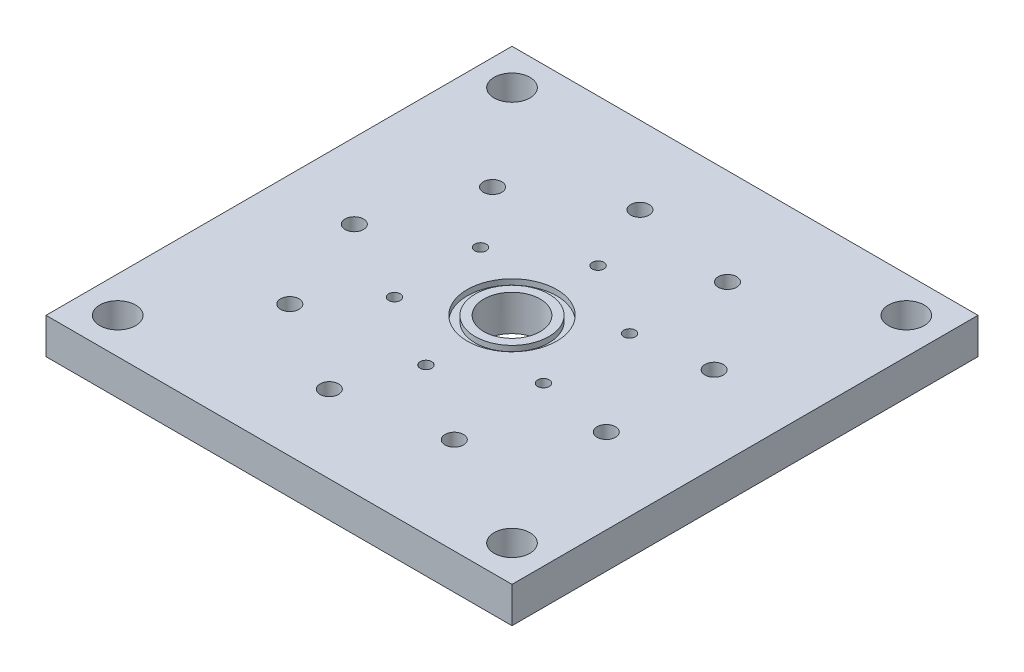
from build123d import *

# Parameters (mm, degrees)
SKETCH1_W           = 82.55
SKETCH1_H           = 82.55
BOSS_EXTRUDE1_DEPTH = 6.35
CUT_EXTRUDE1_REACH  = 8.35
SKETCH2_R           = 4.99999
SKETCH4_R           = 7.9248
SKETCH4_R_2         = 6.5278
CUT_EXTRUDE3_DEPTH  = 0.9779
SKETCH5_R           = 1.03251
CUT_EXTRUDE4_DEPTH  = 3.175
CIRPATTERN1_COUNT   = 6
SKETCH6_R           = 1.63195
CUT_EXTRUDE5_DEPTH  = 6.35
CIRPATTERN2_COUNT   = 9
CUT_EXTRUDE6_REACH  = 8.35
SKETCH7_R           = 3.175


with BuildPart() as part:
    # Sketch1 → Boss-Extrude1 (new body)
    with BuildSketch(Plane(origin=(0, 0, 0), x_dir=(1, 0, 0), z_dir=(0, 1, 0))):
        Rectangle(SKETCH1_W, SKETCH1_H)
    extrude(amount=BOSS_EXTRUDE1_DEPTH)

    # Sketch2 → Cut-Extrude1 (cut, up to next)
    with BuildSketch(Plane(origin=(0, 6.35, 0), x_dir=(1, 0, 0), z_dir=(0, 1, 0)), mode=Mode.PRIVATE) as cut_extrude1_sk1:
        Circle(SKETCH2_R)
    cut_extrude1_tool1 = extrude(cut_extrude1_sk1.sketch, amount=-CUT_EXTRUDE1_REACH, mode=Mode.PRIVATE) & part.part
    add(cut_extrude1_tool1.solids().sort_by_distance((0, 6.35, 0))[0], mode=Mode.SUBTRACT)

    # Sketch4 → Cut-Extrude3 (cut)
    with BuildSketch(Plane(origin=(0, 6.35, 0), x_dir=(1, 0, 0), z_dir=(0, 1, 0))):
        Circle(SKETCH4_R)
        Circle(SKETCH4_R_2, mode=Mode.SUBTRACT)
    extrude(amount=-CUT_EXTRUDE3_DEPTH, mode=Mode.SUBTRACT)

    # Sketch5 → Cut-Extrude4 (cut)
    with BuildSketch(Plane(origin=(0, 6.35, 0), x_dir=(1, 0, 0), z_dir=(0, 1, 0))):
        with Locations((0, -15.24)):
            Circle(SKETCH5_R)
    cut_extrude4 = extrude(amount=-CUT_EXTRUDE4_DEPTH, mode=Mode.SUBTRACT)

    # CirPattern1: Cut-Extrude4 ×6 about axis
    cirpattern1_axis = Axis((0, 0, 0), (0, 1, 0))
    for i in range(1, CIRPATTERN1_COUNT):
        add(cut_extrude4.rotate(cirpattern1_axis, i * 360 / CIRPATTERN1_COUNT), mode=Mode.SUBTRACT)

    # Sketch6 → Cut-Extrude5 (cut)
    with BuildSketch(Plane(origin=(0, 6.35, 0), x_dir=(1, 0, 0), z_dir=(0, 1, 0))):
        with Locations((13.97, -24.196749782)):
            Circle(SKETCH6_R)
    cut_extrude5 = extrude(amount=-CUT_EXTRUDE5_DEPTH, mode=Mode.SUBTRACT)

    # CirPattern2: Cut-Extrude5 ×9 about axis
    cirpattern2_axis = Axis((0, 0, 0), (0, 1, 0))
    for i in range(1, CIRPATTERN2_COUNT):
        add(cut_extrude5.rotate(cirpattern2_axis, i * 360 / CIRPATTERN2_COUNT), mode=Mode.SUBTRACT)

    # Sketch7 → Cut-Extrude6 (cut, up to next)
    with BuildSketch(Plane(origin=(0, 6.35, 0), x_dir=(1, 0, 0), z_dir=(0, 1, 0)), mode=Mode.PRIVATE) as cut_extrude6_sk1:
        with Locations((34.925, 34.925)):
            Circle(SKETCH7_R)
    cut_extrude6_tool1 = extrude(cut_extrude6_sk1.sketch, amount=-CUT_EXTRUDE6_REACH, mode=Mode.PRIVATE) & part.part
    add(cut_extrude6_tool1.solids().sort_by_distance((34.925, 6.35, -34.925))[0], mode=Mode.SUBTRACT)
    # Sketch7 → Cut-Extrude6 (cut, up to next)
    with BuildSketch(Plane(origin=(0, 6.35, 0), x_dir=(1, 0, 0), z_dir=(0, 1, 0)), mode=Mode.PRIVATE) as cut_extrude6_sk2:
        with Locations((34.925, -34.925)):
            Circle(SKETCH7_R)
    cut_extrude6_tool2 = extrude(cut_extrude6_sk2.sketch, amount=-CUT_EXTRUDE6_REACH, mode=Mode.PRIVATE) & part.part
    add(cut_extrude6_tool2.solids().sort_by_distance((34.925, 6.35, 34.925))[0], mode=Mode.SUBTRACT)
    # Sketch7 → Cut-Extrude6 (cut, up to next)
    with BuildSketch(Plane(origin=(0, 6.35, 0), x_dir=(1, 0, 0), z_dir=(0, 1, 0)), mode=Mode.PRIVATE) as cut_extrude6_sk3:
        with Locations((-34.925, -34.925)):
            Circle(SKETCH7_R)
    cut_extrude6_tool3 = extrude(cut_extrude6_sk3.sketch, amount=-CUT_EXTRUDE6_REACH, mode=Mode.PRIVATE) & part.part
    add(cut_extrude6_tool3.solids().sort_by_distance((-34.925, 6.35, 34.925))[0], mode=Mode.SUBTRACT)
    # Sketch7 → Cut-Extrude6 (cut, up to next)
    with BuildSketch(Plane(origin=(0, 6.35, 0), x_dir=(1, 0, 0), z_dir=(0, 1, 0)), mode=Mode.PRIVATE) as cut_extrude6_sk4:
        with Locations((-34.925, 34.925)):
            Circle(SKETCH7_R)
    cut_extrude6_tool4 = extrude(cut_extrude6_sk4.sketch, amount=-CUT_EXTRUDE6_REACH, mode=Mode.PRIVATE) & part.part
    add(cut_extrude6_tool4.solids().sort_by_distance((-34.925, 6.35, -34.925))[0], mode=Mode.SUBTRACT)


solid = part.part
